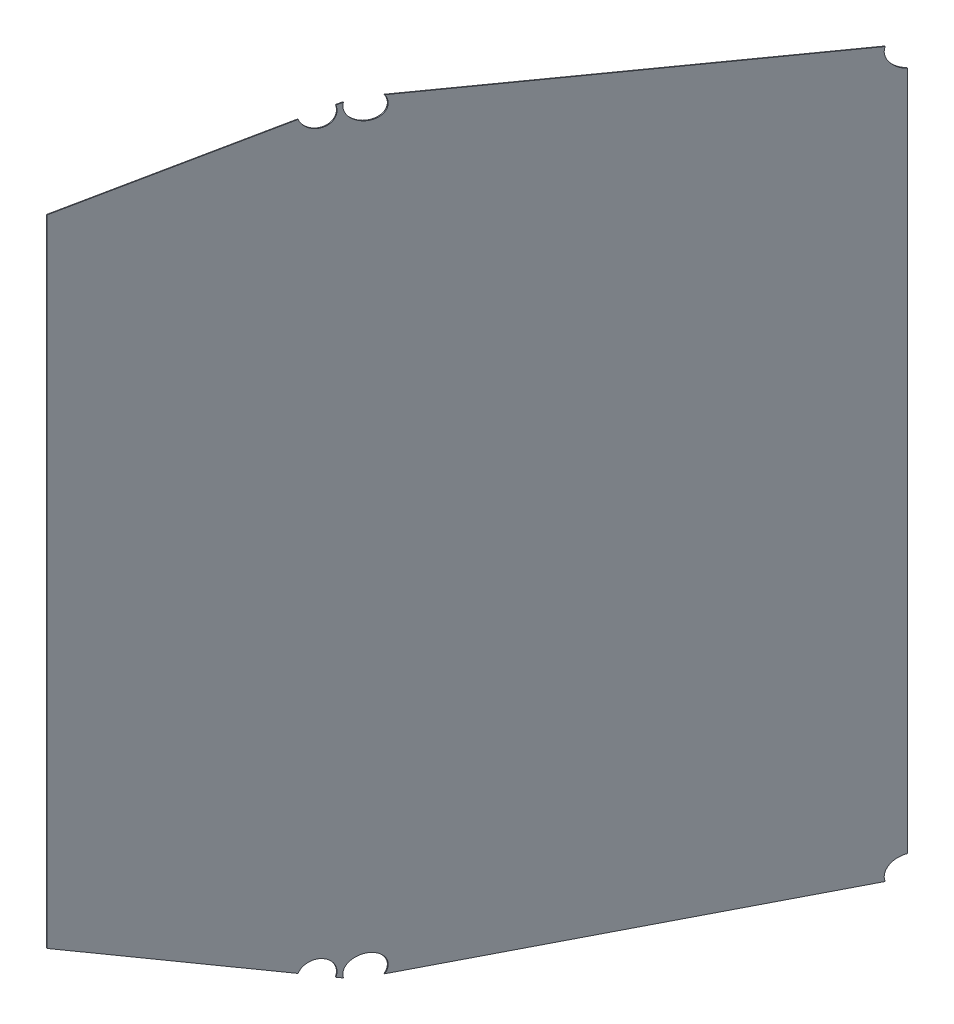
from build123d import *

# Parameters (mm, degrees)
BOSS_EXTRUDE1_DEPTH = 0.3175
SKETCH4_R           = 12.8905
CUT_EXTRUDE1_DEPTH  = 152.4
SKETCH5_R           = 12.8905
CUT_EXTRUDE2_DEPTH  = 152.4
SKETCH6_R           = 12.8905
CUT_EXTRUDE3_DEPTH  = 152.4


with BuildPart() as part:
    # Sketch3 → Boss-Extrude1 (new body, symmetric)
    with BuildSketch(Plane(origin=(348.778890993, 0, 212.329779666), x_dir=(0.519999813, 0, -0.854166374), z_dir=(0.854166374, 0, 0.519999813))):
        Polygon((310.98364901, 0), (310.98364901, 336.55), (-63.66635099, 356.184574508), (-273.21635099, 296.314909512), (-273.21635099, 0), align=None)
        Polygon((310.98364901, -336.55), (310.98364901, 0), (-273.21635099, 0), (-273.21635099, -296.314909512), (-63.66635099, -356.184574508), align=None)
    extrude(amount=BOSS_EXTRUDE1_DEPTH, both=True)

    # Sketch4 → Cut-Extrude1 (cut)
    with BuildSketch(Plane(origin=(381.685291714, 370.332, -52.606299668), x_dir=(0, 0, 1), z_dir=(-0.956162433, 0.292836818, 0))):
        Circle(SKETCH4_R)
    cut_extrude1 = extrude(amount=-CUT_EXTRUDE1_DEPTH, mode=Mode.SUBTRACT)

    # Sketch5 → Cut-Extrude2 (cut)
    with BuildSketch(Plane(origin=(197.535291714, 368.359946538, 264.893700332), x_dir=(0.030514213, -0.004769179, 0.999522955), z_dir=(-0.987534126, 0.154345353, 0.030884661))):
        Circle(SKETCH5_R)
    cut_extrude2 = extrude(amount=-CUT_EXTRUDE2_DEPTH, mode=Mode.SUBTRACT)

    # Sketch6 → Cut-Extrude3 (cut)
    with BuildSketch(Plane(origin=(197.535291714, 368.359946538, 264.893700332), x_dir=(-0.218520162, 0.041163819, 0.974963835), z_dir=(-0.958112576, 0.180484822, -0.222363489))):
        Circle(SKETCH6_R)
    cut_extrude3 = extrude(amount=-CUT_EXTRUDE3_DEPTH, mode=Mode.SUBTRACT)

    # Mirror1: Cut-Extrude1, Cut-Extrude2, Cut-Extrude3 across plane
    add(cut_extrude1.mirror(Plane.ZX), mode=Mode.SUBTRACT)
    add(cut_extrude2.mirror(Plane.ZX), mode=Mode.SUBTRACT)
    add(cut_extrude3.mirror(Plane.ZX), mode=Mode.SUBTRACT)


solid = part.part
